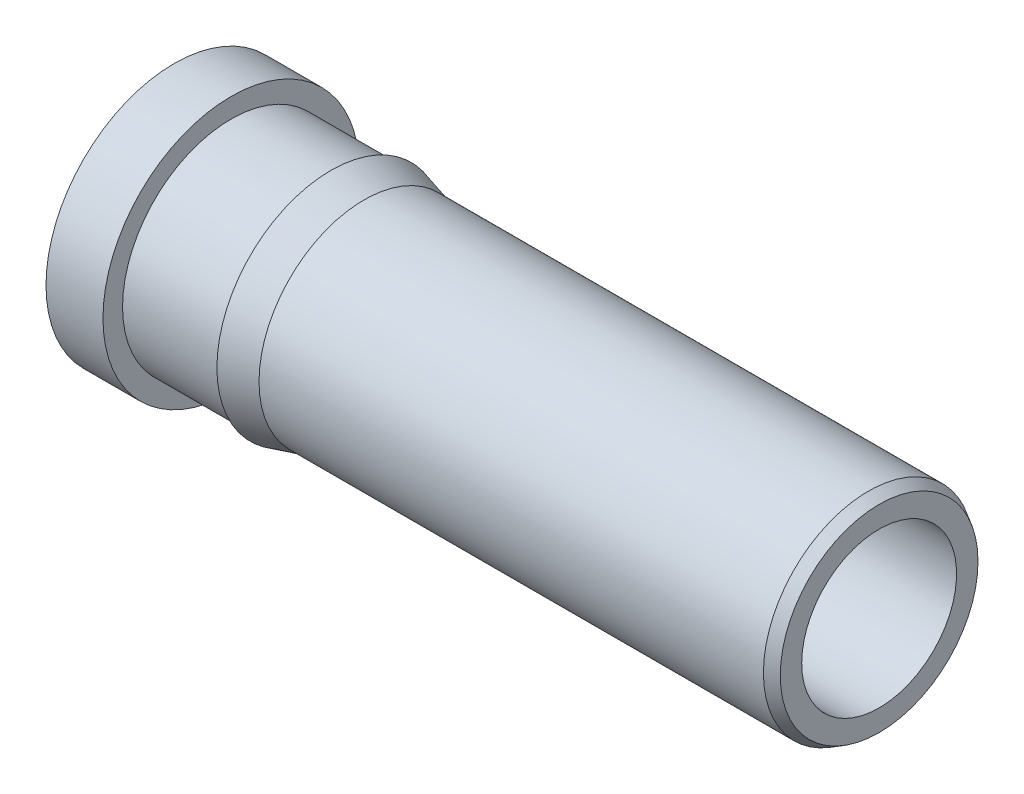
from build123d import *

# Parameters (mm, degrees)
HOLE1_D     = 1.2954
HOLE1_DEPTH = 3.1496
HOLE1_TIP   = 0.389177423
HOLE2_D     = 1.1049
HOLE2_DEPTH = 5.0292
HOLE2_TIP   = 0.331945449


with BuildPart() as part:
    # Sketch1 → RevolutionAngle1 (revolve)
    with BuildSketch(Plane.XY):
        Polygon((0, 0), (0, 0.9144), (0.4064, 0.9144), (0.4064, 0.7747), (1.1176, 0.7747), (1.1176, 0.8128), (1.354585226, 0.7493), (4.953, 0.7493), (5.0292, 0.705305909), (5.0292, 0), align=None)
    revolve(axis=Axis((0, 0, 0), (1, 0, 0)))

    # Hole1
    with Locations(Plane.ZY):
        with Locations((0, 0)):
            Hole(HOLE1_D / 2, depth=HOLE1_DEPTH)
            with Locations((0, 0, -(HOLE1_DEPTH + HOLE1_TIP / 2))):  # 118° drill point
                Cone(0, HOLE1_D / 2, HOLE1_TIP, mode=Mode.SUBTRACT)

    # Hole2
    with Locations(Plane(origin=(0, 0.34063155, -0.647816844), x_dir=(0, 0, 1), z_dir=(-1, 0, 0))):
        with Locations((0.647816844, -0.34063155)):
            Hole(HOLE2_D / 2, depth=HOLE2_DEPTH)
            with Locations((0, 0, -(HOLE2_DEPTH + HOLE2_TIP / 2))):  # 118° drill point
                Cone(0, HOLE2_D / 2, HOLE2_TIP, mode=Mode.SUBTRACT)


solid = part.part
